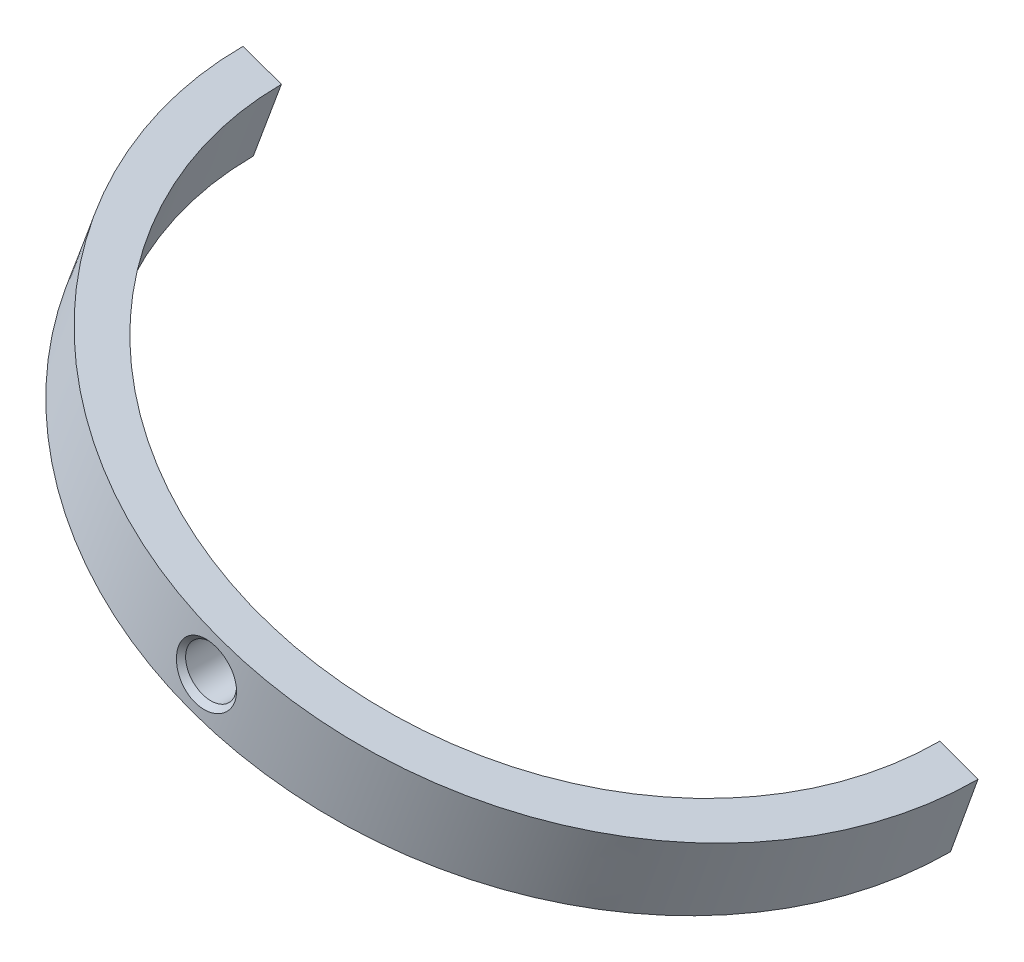
from build123d import *

# Parameters (mm, degrees)
ROTOVAT1_ANGLE        = 180
M3_Z_VIT1_D           = 2.5
M3_Z_VIT1_DEPTH       = 19.288970198
M3_Z_VIT1_CSINK_D     = 3.05
M3_Z_VIT1_CSINK_ANGLE = 90


with BuildPart() as part:
    # Skica1 → Rotovat1 (revolve)
    with BuildSketch(Plane.XY):
        Polygon((-358.493859674, -32.75993206), (-357.140613979, -28.995817934), (-359.020013823, -28.311772333), (-360.370342902, -32.067773761), align=None)
    revolve(axis=Axis((-372.880596884, -16.019433279, 0), (-0.342020143, -0.939692621, 0)), revolution_arc=ROTOVAT1_ANGLE)

    # M3 závit1
    with Locations(Plane(origin=(-375.894265461, -24.29837465, 19.236814653), x_dir=(0, 0.999993116, -0.003710613), z_dir=(0.00133078, 0.00371061, 0.99999223))):
        with Locations((0, 0)):
            CounterSinkHole(M3_Z_VIT1_D / 2, M3_Z_VIT1_CSINK_D / 2, depth=M3_Z_VIT1_DEPTH, counter_sink_angle=M3_Z_VIT1_CSINK_ANGLE)


solid = part.part
